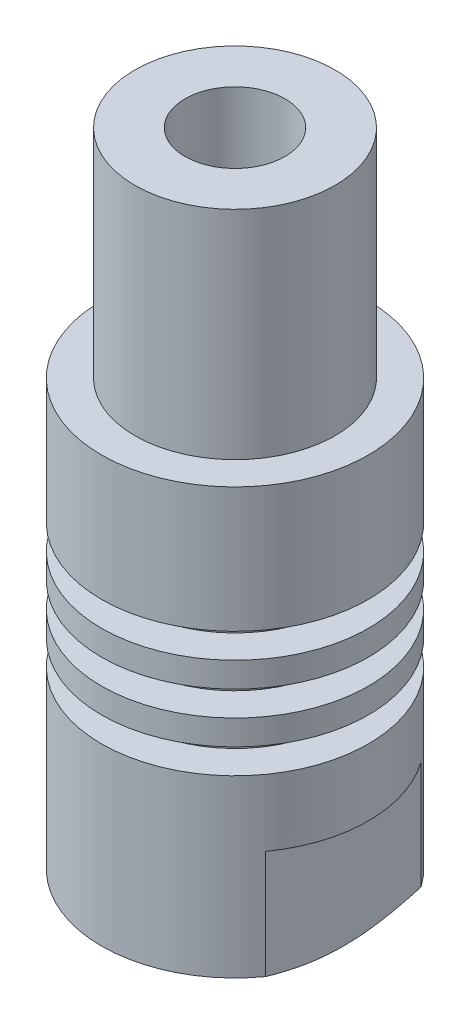
from build123d import *

# Parameters (mm, degrees)
TAGLIO_ESTRUSIONE1_REACH             = 10
SCHIZZO2_W                           = 1.5
SCHIZZO2_H                           = 8
TAGLIO_ESTRUSIONE1_DIRECTION_2_REACH = 10
SCHIZZO7_R                           = 3
TAGLIO_ESTRUSIONE2_DEPTH             = 41
FORO_FILETTATO_M8_1_D                = 6.8
FORO_FILETTATO_M8_1_DEPTH            = 12
FORO_FILETTATO_M8_1_TIP              = 2.042926105
SCHIZZO10_OUTSIDE_W                  = 27.192
SCHIZZO10_OUTSIDE_H                  = 27.192
SCHIZZO10_OUTSIDE_R                  = 6
TAGLIO_ESTRUSIONE3_DEPTH             = 13


with BuildPart() as part:
    # Schizzo1 → Rivoluzione1 (revolve)
    with BuildSketch(Plane.XY):
        Polygon((0, 0), (-5, 0), (-8, 1.5), (-8, 12), (-6, 12), (-6, 13.5), (-8, 13.5), (-8, 15), (-6, 15), (-6, 16.5), (-8, 16.5), (-8, 18), (-6, 18), (-6, 19.5), (-8, 19.5), (-8, 27), (-8, 40), (0, 40), align=None)
    revolve(axis=Axis((0, 129.407380346, 0), (0, -1, 0)))

    # Schizzo2 → Taglio-Estrusione1 (cut, up to next)
    with BuildSketch(Plane.XY, mode=Mode.PRIVATE) as taglio_estrusione1_sk1:
        with Locations((-7.25, 4)):
            Rectangle(SCHIZZO2_W, SCHIZZO2_H)
    taglio_estrusione1_tool1 = extrude(taglio_estrusione1_sk1.sketch, amount=-TAGLIO_ESTRUSIONE1_REACH, mode=Mode.PRIVATE) & part.part
    add(taglio_estrusione1_tool1.solids().sort_by_distance((-7.25, 4, 0))[0], mode=Mode.SUBTRACT)
    # Schizzo2 → Taglio-Estrusione1 (cut, up to next)
    with BuildSketch(Plane.XY, mode=Mode.PRIVATE) as taglio_estrusione1_sk2:
        with Locations((7.25, 4)):
            Rectangle(SCHIZZO2_W, SCHIZZO2_H)
    taglio_estrusione1_tool2 = extrude(taglio_estrusione1_sk2.sketch, amount=-TAGLIO_ESTRUSIONE1_REACH, mode=Mode.PRIVATE) & part.part
    add(taglio_estrusione1_tool2.solids().sort_by_distance((7.25, 4, 0))[0], mode=Mode.SUBTRACT)

    # Schizzo2 → Taglio-Estrusione1 direction 2 (cut, up to next)
    with BuildSketch(Plane.XY, mode=Mode.PRIVATE) as taglio_estrusione1_direction_2_sk1:
        with Locations((-7.25, 4)):
            Rectangle(SCHIZZO2_W, SCHIZZO2_H)
    taglio_estrusione1_direction_2_tool1 = extrude(taglio_estrusione1_direction_2_sk1.sketch, amount=TAGLIO_ESTRUSIONE1_DIRECTION_2_REACH, mode=Mode.PRIVATE) & part.part
    add(taglio_estrusione1_direction_2_tool1.solids().sort_by_distance((-7.25, 4, 0))[0], mode=Mode.SUBTRACT)
    # Schizzo2 → Taglio-Estrusione1 direction 2 (cut, up to next)
    with BuildSketch(Plane.XY, mode=Mode.PRIVATE) as taglio_estrusione1_direction_2_sk2:
        with Locations((7.25, 4)):
            Rectangle(SCHIZZO2_W, SCHIZZO2_H)
    taglio_estrusione1_direction_2_tool2 = extrude(taglio_estrusione1_direction_2_sk2.sketch, amount=TAGLIO_ESTRUSIONE1_DIRECTION_2_REACH, mode=Mode.PRIVATE) & part.part
    add(taglio_estrusione1_direction_2_tool2.solids().sort_by_distance((7.25, 4, 0))[0], mode=Mode.SUBTRACT)

    # Schizzo7 → Taglio-Estrusione2 (cut, through all)
    with BuildSketch(Plane(origin=(0, 40, 0), x_dir=(1, 0, 0), z_dir=(0, 1, 0))):
        Circle(SCHIZZO7_R)
    extrude(amount=-TAGLIO_ESTRUSIONE2_DEPTH, mode=Mode.SUBTRACT)

    # Foro filettato M8-1
    with Locations(Plane(origin=(0, 0, 0), x_dir=(-1, 0, 0), z_dir=(0, -1, 0))):
        with Locations((0, 0)):
            Hole(FORO_FILETTATO_M8_1_D / 2, depth=FORO_FILETTATO_M8_1_DEPTH)
            with Locations((0, 0, -(FORO_FILETTATO_M8_1_DEPTH + FORO_FILETTATO_M8_1_TIP / 2))):  # 118° drill point
                Cone(0, FORO_FILETTATO_M8_1_D / 2, FORO_FILETTATO_M8_1_TIP, mode=Mode.SUBTRACT)

    # Schizzo10 outside → Taglio-Estrusione3 (cut)
    with BuildSketch(Plane(origin=(0, 40, 0), x_dir=(1, 0, 0), z_dir=(0, 1, 0))):
        Rectangle(SCHIZZO10_OUTSIDE_W, SCHIZZO10_OUTSIDE_H)
        Circle(SCHIZZO10_OUTSIDE_R, mode=Mode.SUBTRACT)
    extrude(amount=-TAGLIO_ESTRUSIONE3_DEPTH, mode=Mode.SUBTRACT)


solid = part.part
